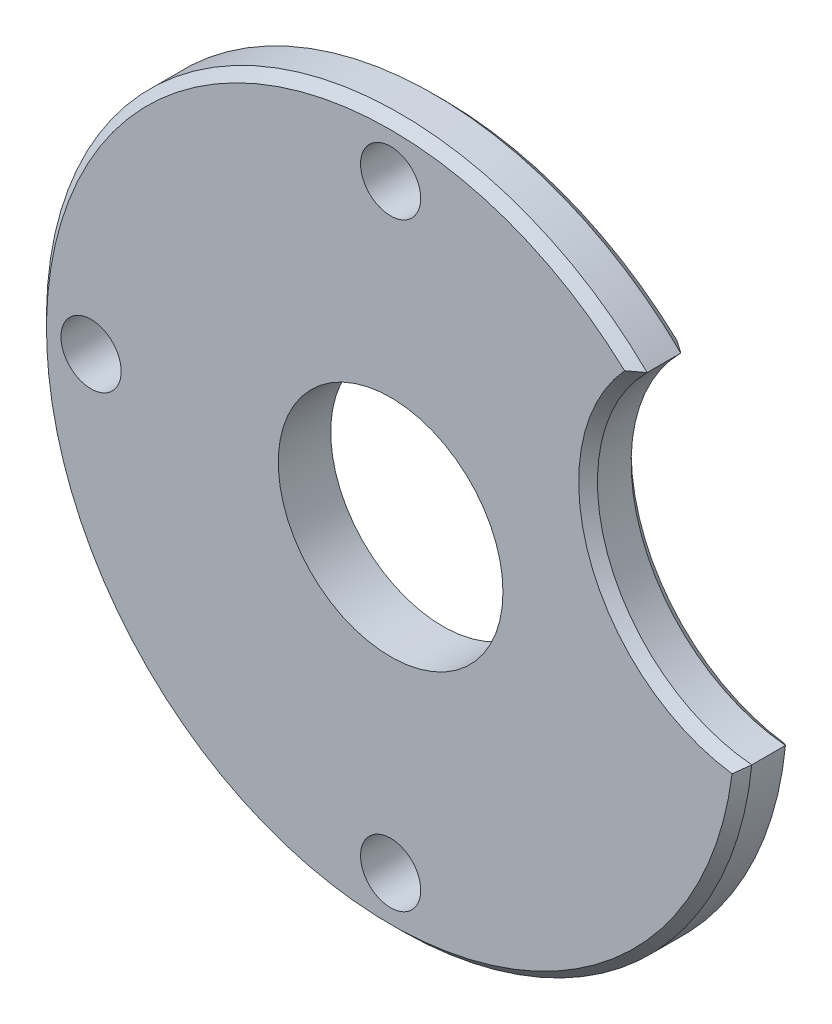
from build123d import *

# Parameters (mm, degrees)
SKETCH1_R           = 2.5527
SKETCH1_R_2         = 9.525
BOSS_EXTRUDE1_DEPTH = 4.445
CHAMFER1_SIZE       = 0.79375
CHAMFER2_SIZE       = 0.79375


with BuildPart() as part:
    # Sketch1 → Boss-Extrude1 (new body)
    with BuildSketch(Plane.XY):
        with BuildLine():
            ThreePointArc((29.827123218, -2.94338318), (17.602792019, 6.406892335), (20.956931757, 21.427267566))
            ThreePointArc((20.956931757, 21.427267566), (-28.16446723, -10.251027736), (29.827123218, -2.94338318))
        make_face()
        with Locations((0, -25.4)):
            Circle(SKETCH1_R, mode=Mode.SUBTRACT)
        with Locations((-25.4, 0)):
            Circle(SKETCH1_R, mode=Mode.SUBTRACT)
        Circle(SKETCH1_R_2, mode=Mode.SUBTRACT)
        with Locations((0, 25.4)):
            Circle(SKETCH1_R, mode=Mode.SUBTRACT)
    extrude(amount=BOSS_EXTRUDE1_DEPTH)

    # Chamfer1
    chamfer1_edges = [part.edges().sort_by_distance(p)[0] for p in [
        (17.602792019, 6.406892335, 4.445),
        (-28.16446723, -10.251027736, 4.445),
    ]]
    chamfer(chamfer1_edges, length=CHAMFER1_SIZE)

    # Chamfer2
    chamfer2_edges = [part.edges().sort_by_distance(p)[0] for p in [
        (-28.16446723, -10.251027736, 0),
        (17.602792019, 6.406892335, 0),
    ]]
    chamfer(chamfer2_edges, length=CHAMFER2_SIZE)


solid = part.part
